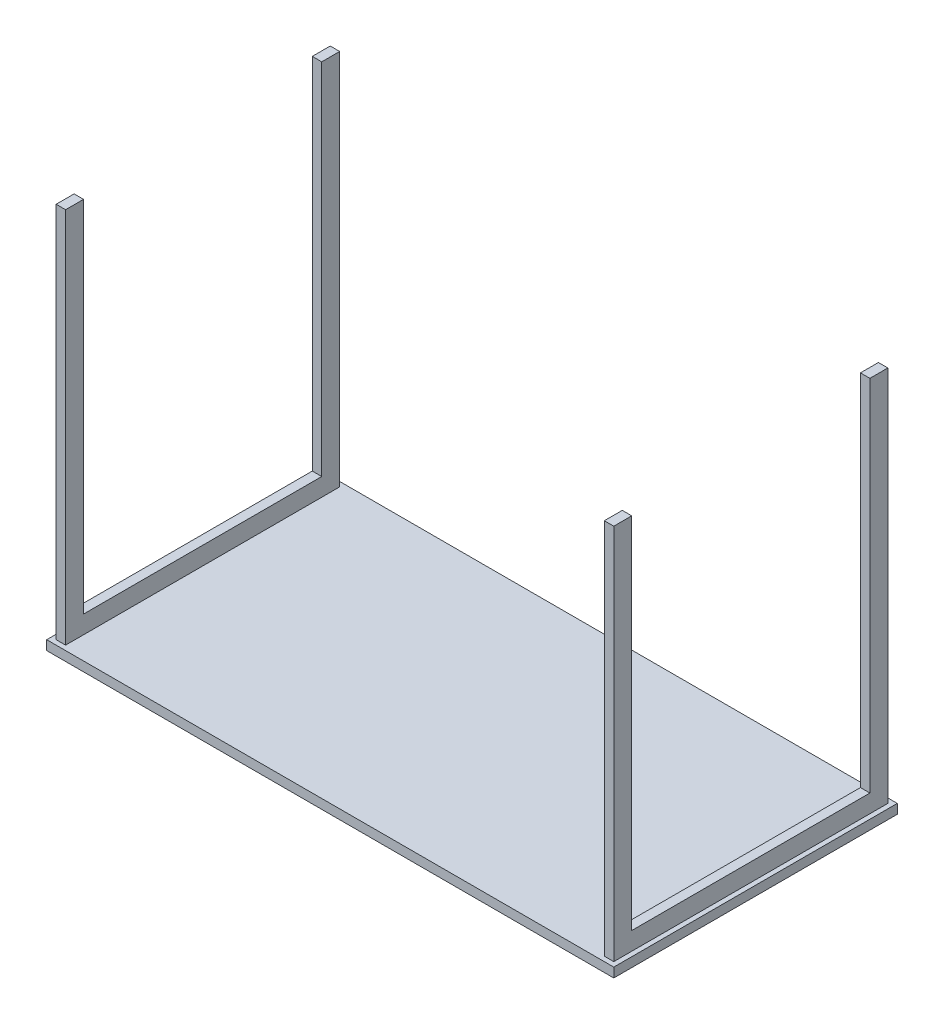
from build123d import *

# Parameters (mm, degrees)
SKETCH9_W           = 1200
SKETCH9_H           = 600
BOSS_EXTRUDE4_DEPTH = 20
SKETCH10_W          = 20
SKETCH10_H          = 580
BOSS_EXTRUDE6_DEPTH = 38
SKETCH11_W          = 20
SKETCH11_H          = 38
BOSS_EXTRUDE7_DEPTH = 760


with BuildPart() as part:
    # Sketch9 → Boss-Extrude4 (new body)
    with BuildSketch(Plane(origin=(0, 0, 0), x_dir=(1, 0, 0), z_dir=(0, 1, 0))):
        with Locations((600, 300)):
            Rectangle(SKETCH9_W, SKETCH9_H)
    extrude(amount=BOSS_EXTRUDE4_DEPTH)

    # Sketch10 → Boss-Extrude6 (add)
    with BuildSketch(Plane(origin=(0, 20, 0), x_dir=(1, 0, 0), z_dir=(0, 1, 0))):
        with Locations((20, 300)):
            Rectangle(SKETCH10_W, SKETCH10_H)
        with Locations((1180, 300)):
            Rectangle(SKETCH10_W, SKETCH10_H)
    extrude(amount=BOSS_EXTRUDE6_DEPTH)

    # Sketch11 → Boss-Extrude7 (add)
    with BuildSketch(Plane(origin=(0, 58, 0), x_dir=(1, 0, 0), z_dir=(0, 1, 0))):
        with Locations((20, 571)):
            Rectangle(SKETCH11_W, SKETCH11_H)
        with Locations((20, 29)):
            Rectangle(SKETCH11_W, SKETCH11_H)
        with Locations((1180, 29)):
            Rectangle(SKETCH11_W, SKETCH11_H)
        with Locations((1180, 571)):
            Rectangle(SKETCH11_W, SKETCH11_H)
    extrude(amount=BOSS_EXTRUDE7_DEPTH)


solid = part.part
